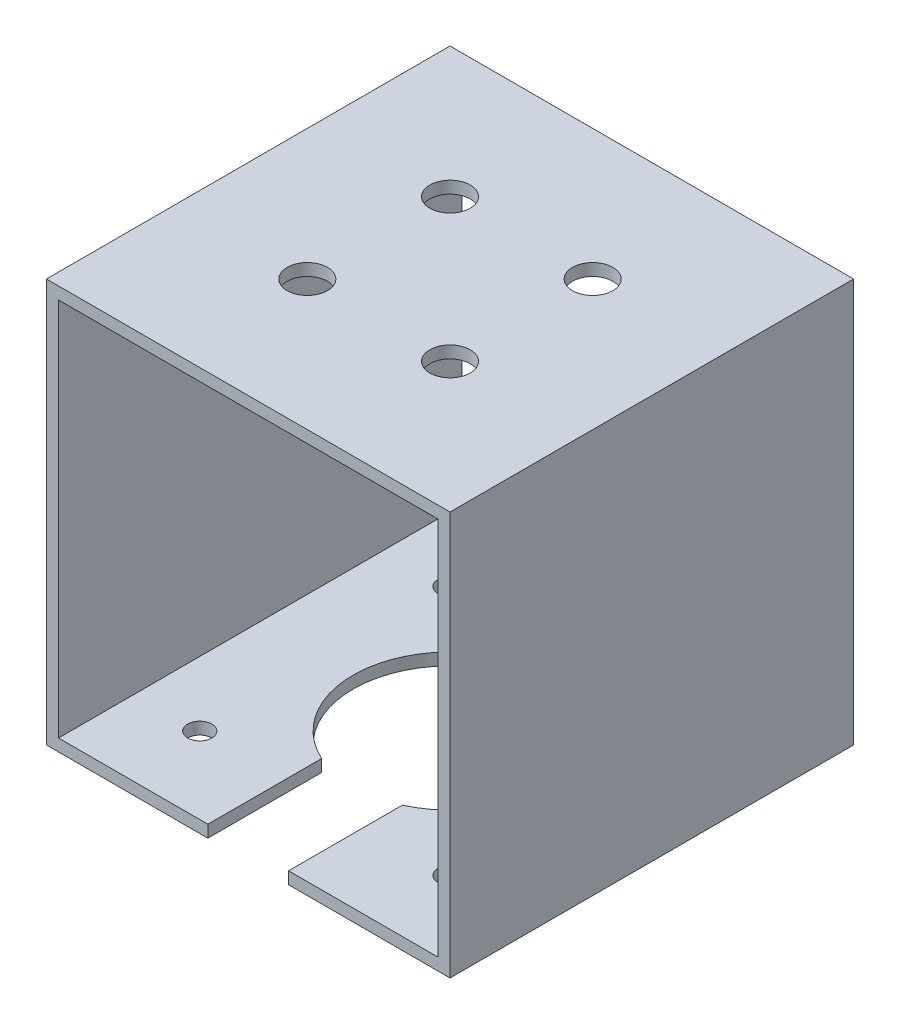
from build123d import *

# Parameters (mm, degrees)
ESBO_O1_W                = 50
ESBO_O1_H                = 50
ESBO_O1_W_2              = 47
ESBO_O1_H_2              = 47
RESSALTO_EXTRUS_O1_DEPTH = 50
ESBO_O2_R                = 2.5
CORTE_EXTRUS_O2_DEPTH    = 10
ESBO_O3_R                = 12
CORTE_EXTRUS_O3_DEPTH    = 10
ESBO_O4_R                = 1.5
CORTE_EXTRUS_O5_DEPTH    = 10
ESBO_O5_W                = 10
ESBO_O5_H                = 36.830257898
CORTE_EXTRUS_O6_DEPTH    = 10


with BuildPart() as part:
    # Esboço1 → Ressalto-extrusão1 (new body)
    with BuildSketch(Plane.XY):
        Rectangle(ESBO_O1_W, ESBO_O1_H)
        Rectangle(ESBO_O1_W_2, ESBO_O1_H_2, mode=Mode.SUBTRACT)
    extrude(amount=RESSALTO_EXTRUS_O1_DEPTH)

    # Esboço2 → Corte-extrusão2 (cut)
    with BuildSketch(Plane(origin=(0, 25, 0), x_dir=(1, 0, 0), z_dir=(0, 1, 0))):
        with Locations((-8.838834765, -16.161165235)):
            Circle(ESBO_O2_R)
        with Locations((8.838834765, -16.161165235)):
            Circle(ESBO_O2_R)
        with Locations((-8.838834765, -33.838834765)):
            Circle(ESBO_O2_R)
        with Locations((8.838834765, -33.838834765)):
            Circle(ESBO_O2_R)
    extrude(amount=-CORTE_EXTRUS_O2_DEPTH, mode=Mode.SUBTRACT)

    # Esboço3 → Corte-extrusão3 (cut)
    with BuildSketch(Plane(origin=(0, -23.5, 0), x_dir=(1, 0, 0), z_dir=(0, 1, 0))):
        with Locations((0, -25)):
            Circle(ESBO_O3_R)
    extrude(amount=-CORTE_EXTRUS_O3_DEPTH, mode=Mode.SUBTRACT)

    # Esboço4 → Corte-extrusão5 (cut)
    with BuildSketch(Plane.XZ.offset(25)):
        with Locations((15.5, 40.5)):
            Circle(ESBO_O4_R)
        with Locations((15.5, 9.5)):
            Circle(ESBO_O4_R)
        with Locations((-15.5, 40.5)):
            Circle(ESBO_O4_R)
        with Locations((-15.5, 9.5)):
            Circle(ESBO_O4_R)
    extrude(amount=-CORTE_EXTRUS_O5_DEPTH, mode=Mode.SUBTRACT)

    # Esboço5 → Corte-extrusão6 (cut)
    with BuildSketch(Plane.XZ.offset(25)):
        with Locations((0, 50)):
            Rectangle(ESBO_O5_W, ESBO_O5_H)
    extrude(amount=-CORTE_EXTRUS_O6_DEPTH, mode=Mode.SUBTRACT)


solid = part.part
